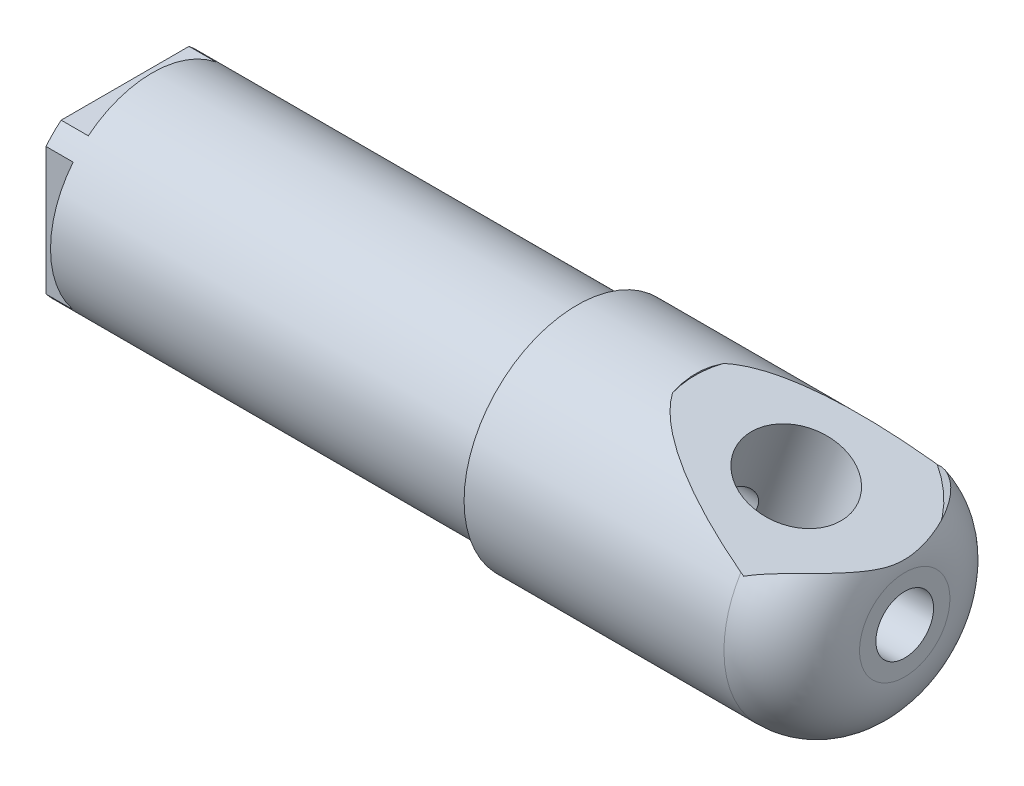
from build123d import *

# Parameters (mm, degrees)
SKETCH1_R               = 10
BOSS_EXTRUDE1_DEPTH     = 69
SKETCH9_OUTSIDE_W       = 36.914
SKETCH9_OUTSIDE_H       = 36.914
SKETCH9_OUTSIDE_R       = 9
CUT_EXTRUDE5_DEPTH      = 40
SKETCH2_OUTSIDE_W       = 36.914
SKETCH2_OUTSIDE_H       = 36.914
SKETCH2_OUTSIDE_W_2     = 14
SKETCH2_OUTSIDE_H_2     = 14
CUT_EXTRUDE1_DEPTH      = 2.4
F_1_4_20_TAPPED_HOLE1_D = 5.1054
FILLET2_R               = 6
CUT_EXTRUDE2_DEPTH      = 59.72818744
CUT_EXTRUDE2_DEPTH_BACK = 59.72818744
SKETCH7_R               = 4.2164
CUT_EXTRUDE3_START      = 7
SKETCH8_R               = 9.525
CUT_EXTRUDE3_DEPTH      = 52.728187572


with BuildPart() as part:
    # Sketch1 → Boss-Extrude1 (new body)
    with BuildSketch(Plane(origin=(0, 0, 0), x_dir=(0, 0, -1), z_dir=(1, 0, 0))):
        Circle(SKETCH1_R)
    extrude(amount=BOSS_EXTRUDE1_DEPTH)

    # Sketch9 outside → Cut-Extrude5 (cut)
    with BuildSketch(Plane.ZY):
        Rectangle(SKETCH9_OUTSIDE_W, SKETCH9_OUTSIDE_H)
        Circle(SKETCH9_OUTSIDE_R, mode=Mode.SUBTRACT)
    extrude(amount=-CUT_EXTRUDE5_DEPTH, mode=Mode.SUBTRACT)

    # Sketch2 outside → Cut-Extrude1 (cut)
    with BuildSketch(Plane.ZY):
        Rectangle(SKETCH2_OUTSIDE_W, SKETCH2_OUTSIDE_H)
        Rectangle(SKETCH2_OUTSIDE_W_2, SKETCH2_OUTSIDE_H_2, mode=Mode.SUBTRACT)
    extrude(amount=-CUT_EXTRUDE1_DEPTH, mode=Mode.SUBTRACT)

    # 1_4-20 Tapped Hole1 (through all)
    with Locations(Plane.ZY):
        with Locations((0, 0)):
            Hole(F_1_4_20_TAPPED_HOLE1_D / 2)

    # Fillet2
    fillet2_edges = [part.edges().sort_by_distance(p)[0] for p in [
        (69, 0, 10),
    ]]
    fillet(fillet2_edges, radius=FILLET2_R)

    # Sketch7 → Cut-Extrude2 (cut, two sides: drawn at the far end of the back side and taken through both)
    with BuildSketch(Plane(origin=(57, 0, 0), x_dir=(0.9396926207859094, -0.3420201433256659, 0), z_dir=(0.3420201433256659, 0.9396926207859094, 0)).offset(-CUT_EXTRUDE2_DEPTH_BACK)):
        Circle(SKETCH7_R)
    extrude(amount=CUT_EXTRUDE2_DEPTH + CUT_EXTRUDE2_DEPTH_BACK, mode=Mode.SUBTRACT)

    # Sketch8 → Cut-Extrude3 (cut, through all)
    with BuildSketch(Plane(origin=(57, 0, 0), x_dir=(0.9396926207859094, -0.3420201433256659, 0), z_dir=(0.3420201433256659, 0.9396926207859094, 0)).offset(CUT_EXTRUDE3_START)):
        Circle(SKETCH8_R)
    extrude(amount=CUT_EXTRUDE3_DEPTH, mode=Mode.SUBTRACT)


solid = part.part
